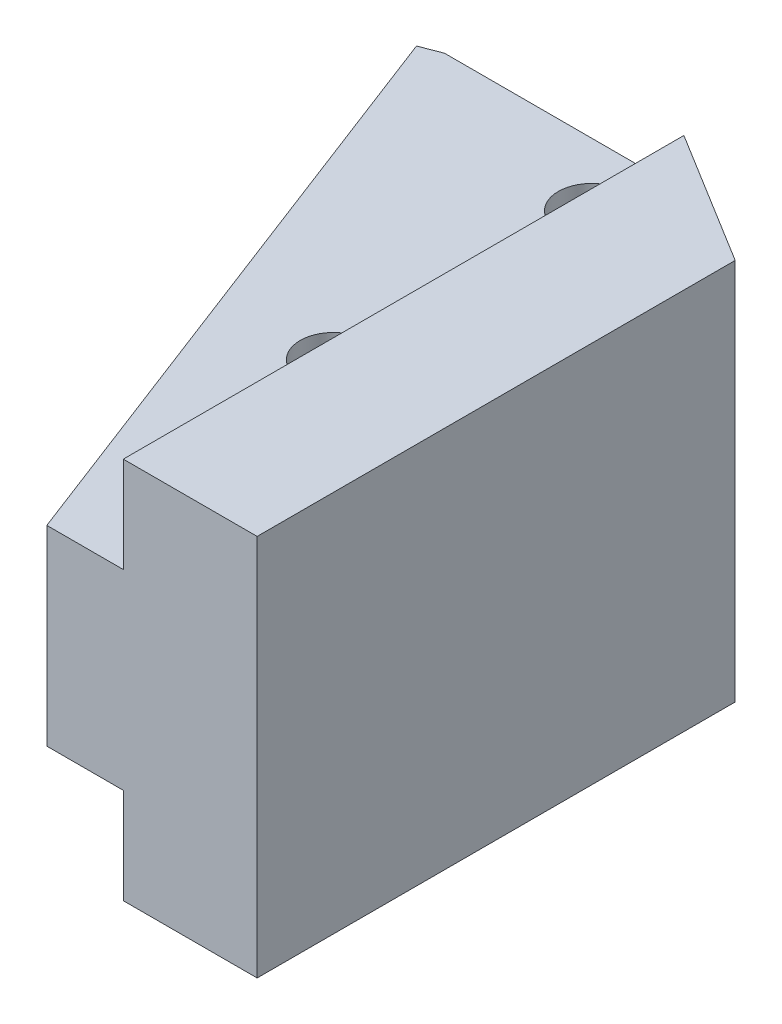
from build123d import *

# Parameters (mm, degrees)
AUFSATZ_LINEAR_AUSTRAGEN1_DEPTH      = 40
AUFSATZ_LINEAR_AUSTRAGEN2_DEPTH      = 10
SCHNITT_LINEAR_AUSTRAGEN1_DEPTH      = 20
SKIZZE5_R                            = 1.75
SCHNITT_LINEAR_AUSTRAGEN2_DEPTH      = 1
SCHNITT_LINEAR_AUSTRAGEN2_DEPTH_BACK = 21


with BuildPart() as part:
    # Skizze1 → Aufsatz-Linear austragen1 (new body)
    with BuildSketch(Plane.XY):
        Polygon((0, 5), (0, -5), (4, -5), (4, -10), (11, -10), (11, 10), (4, 10), (4, 5), align=None)
    extrude(amount=AUFSATZ_LINEAR_AUSTRAGEN1_DEPTH)

    # Skizze2 → Aufsatz-Linear austragen2 (add)
    with BuildSketch(Plane(origin=(0, 5, 0), x_dir=(1, 0, 0), z_dir=(0, 1, 0))):
        Polygon((0, -40), (-12.044350914, -8.623393141), (0, -4), align=None)
    extrude(amount=-AUFSATZ_LINEAR_AUSTRAGEN2_DEPTH)

    # Skizze4 → Schnitt-Linear austragen1 (cut)
    with BuildSketch(Plane(origin=(0, 10, 0), x_dir=(1, 0, 0), z_dir=(0, 1, 0))):
        Polygon((-10.985237261, -8.216837501), (0, -8.216837501), (11, -15), (11, 0), (0, 0), (0, -4), align=None)
    extrude(amount=-SCHNITT_LINEAR_AUSTRAGEN1_DEPTH, mode=Mode.SUBTRACT)

    # Skizze5 → Schnitt-Linear austragen2 (cut, two sides)
    with BuildSketch(Plane(origin=(0, 10, 0), x_dir=(1, 0, 0), z_dir=(0, 1, 0))) as schnitt_linear_austragen2_sk:
        with Locations((0, -25)):
            Circle(SKIZZE5_R)
        with Locations((0, -11.5)):
            Circle(SKIZZE5_R)
    extrude(amount=SCHNITT_LINEAR_AUSTRAGEN2_DEPTH, mode=Mode.SUBTRACT)
    extrude(schnitt_linear_austragen2_sk.sketch, amount=-SCHNITT_LINEAR_AUSTRAGEN2_DEPTH_BACK, mode=Mode.SUBTRACT)


solid = part.part
